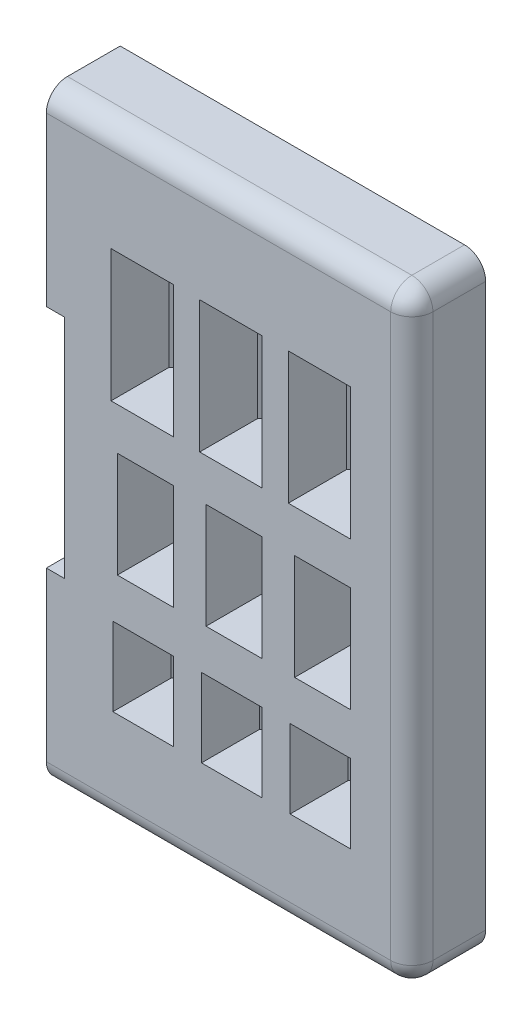
from build123d import *

# Parameters (mm, degrees)
CROQUIS1_W              = 5.9
CROQUIS1_H              = 12.5
CROQUIS1_W_2            = 5.3
CROQUIS1_H_2            = 10
CROQUIS1_W_3            = 5.7277
CROQUIS1_H_3            = 7.4295
SALIENTE_EXTRUIR1_DEPTH = 1
CROQUIS2_W              = 5.9
CROQUIS2_H              = 12.5
CROQUIS2_W_2            = 5.3
CROQUIS2_H_2            = 10
CROQUIS2_W_3            = 5.7277
CROQUIS2_H_3            = 7.4295
SALIENTE_EXTRUIR2_DEPTH = 7
CROQUIS3_W              = 1.2
CROQUIS3_H              = 7.4295
CROQUIS3_H_2            = 10
CROQUIS3_H_3            = 12.5
SALIENTE_EXTRUIR3_DEPTH = 1.5
CHAFL_N1_SIZE           = 1
REDONDEO1_R             = 2


with BuildPart() as part:
    # Croquis1 → Saliente-Extruir1 (new body)
    with BuildSketch(Plane.XY):
        with BuildLine():
            Line((6.325110646, 1.27705094), (31.213497595, 1.27705094))
            ThreePointArc((31.213497595, 1.27705094), (33.334817939, 2.155730596), (34.213497595, 4.27705094))
            Line((34.213497595, 4.27705094), (34.213497595, 46.12294906))
            ThreePointArc((34.213497595, 46.12294906), (33.334817939, 48.244269404), (31.213497595, 49.12294906))
            Line((31.213497595, 49.12294906), (6.325110646, 49.12294906))
            Line((6.325110646, 49.12294906), (6.325110646, 35.928313067))
            Line((6.325110646, 35.928313067), (7.004112389, 35.928313067))
            Line((7.004112389, 35.928313067), (7.004112389, 14.471686933))
            Line((7.004112389, 14.471686933), (6.325110646, 14.471686933))
            Line((6.325110646, 14.471686933), (6.325110646, 1.27705094))
        make_face()
        with Locations((27.45822767, 37.510466453)):
            Rectangle(CROQUIS1_W, CROQUIS1_H, mode=Mode.SUBTRACT)
        with Locations((27.75822767, 22.260466453)):
            Rectangle(CROQUIS1_W_2, CROQUIS1_H_2, mode=Mode.SUBTRACT)
        with Locations((27.54437767, 9.545716453)):
            Rectangle(CROQUIS1_W_3, CROQUIS1_H_3, mode=Mode.SUBTRACT)
        with Locations((19.05822767, 37.510466453)):
            Rectangle(CROQUIS1_W, CROQUIS1_H, mode=Mode.SUBTRACT)
        with Locations((19.35822767, 22.260466453)):
            Rectangle(CROQUIS1_W_2, CROQUIS1_H_2, mode=Mode.SUBTRACT)
        with Locations((19.14437767, 9.545716453)):
            Rectangle(CROQUIS1_W_3, CROQUIS1_H_3, mode=Mode.SUBTRACT)
        with Locations((10.65822767, 37.510466453)):
            Rectangle(CROQUIS1_W, CROQUIS1_H, mode=Mode.SUBTRACT)
        with Locations((10.95822767, 22.260466453)):
            Rectangle(CROQUIS1_W_2, CROQUIS1_H_2, mode=Mode.SUBTRACT)
        with Locations((10.74437767, 9.545716453)):
            Rectangle(CROQUIS1_W_3, CROQUIS1_H_3, mode=Mode.SUBTRACT)
    extrude(amount=-SALIENTE_EXTRUIR1_DEPTH)

    # Croquis2 → Saliente-Extruir2 (add)
    with BuildSketch(Plane.XY):
        Polygon((36.213497595, 53.820046244), (1.576275643, 53.820046244), (1.576275643, 35.928313067), (3.319198905, 35.928313067), (3.319198905, 14.471686933), (1.576275643, 14.471686933), (1.576275643, -3.420839566), (36.213497595, -3.420839566), align=None)
        with Locations((27.45822767, 37.510466453)):
            Rectangle(CROQUIS2_W, CROQUIS2_H, mode=Mode.SUBTRACT)
        with Locations((27.75822767, 22.260466453)):
            Rectangle(CROQUIS2_W_2, CROQUIS2_H_2, mode=Mode.SUBTRACT)
        with Locations((27.54437767, 9.545716453)):
            Rectangle(CROQUIS2_W_3, CROQUIS2_H_3, mode=Mode.SUBTRACT)
        with Locations((19.14437767, 9.545716453)):
            Rectangle(CROQUIS2_W_3, CROQUIS2_H_3, mode=Mode.SUBTRACT)
        with Locations((19.35822767, 22.260466453)):
            Rectangle(CROQUIS2_W_2, CROQUIS2_H_2, mode=Mode.SUBTRACT)
        with Locations((19.05822767, 37.510466453)):
            Rectangle(CROQUIS2_W, CROQUIS2_H, mode=Mode.SUBTRACT)
        with Locations((10.65822767, 37.510466453)):
            Rectangle(CROQUIS2_W, CROQUIS2_H, mode=Mode.SUBTRACT)
        with Locations((10.95822767, 22.260466453)):
            Rectangle(CROQUIS2_W_2, CROQUIS2_H_2, mode=Mode.SUBTRACT)
        with Locations((10.74437767, 9.545716453)):
            Rectangle(CROQUIS2_W_3, CROQUIS2_H_3, mode=Mode.SUBTRACT)
    extrude(amount=SALIENTE_EXTRUIR2_DEPTH)

    # Croquis3 → Saliente-Extruir3 (add)
    with BuildSketch(Plane(origin=(0, 0, -1), x_dir=(-1, 0, 0), z_dir=(0, 0, -1))):
        with Locations((-29.80822767, 9.545716453)):
            Rectangle(CROQUIS3_W, CROQUIS3_H)
        with Locations((-21.40822767, 9.545716453)):
            Rectangle(CROQUIS3_W, CROQUIS3_H)
        with Locations((-25.28052767, 9.545716453)):
            Rectangle(CROQUIS3_W, CROQUIS3_H)
        with Locations((-16.88052767, 9.545716453)):
            Rectangle(CROQUIS3_W, CROQUIS3_H)
        with Locations((-13.00822767, 9.545716453)):
            Rectangle(CROQUIS3_W, CROQUIS3_H)
        with Locations((-8.48052767, 9.545716453)):
            Rectangle(CROQUIS3_W, CROQUIS3_H)
        with Locations((-29.80822767, 22.260466453)):
            Rectangle(CROQUIS3_W, CROQUIS3_H_2)
        with Locations((-21.40822767, 22.260466453)):
            Rectangle(CROQUIS3_W, CROQUIS3_H_2)
        with Locations((-25.70822767, 22.260466453)):
            Rectangle(CROQUIS3_W, CROQUIS3_H_2)
        with Locations((-17.30822767, 22.260466453)):
            Rectangle(CROQUIS3_W, CROQUIS3_H_2)
        with Locations((-13.00822767, 22.260466453)):
            Rectangle(CROQUIS3_W, CROQUIS3_H_2)
        with Locations((-8.90822767, 22.260466453)):
            Rectangle(CROQUIS3_W, CROQUIS3_H_2)
        with Locations((-29.80822767, 37.510466453)):
            Rectangle(CROQUIS3_W, CROQUIS3_H_3)
        with Locations((-25.10822767, 37.510466453)):
            Rectangle(CROQUIS3_W, CROQUIS3_H_3)
        with Locations((-21.40822767, 37.510466453)):
            Rectangle(CROQUIS3_W, CROQUIS3_H_3)
        with Locations((-16.70822767, 37.510466453)):
            Rectangle(CROQUIS3_W, CROQUIS3_H_3)
        with Locations((-13.00822767, 37.510466453)):
            Rectangle(CROQUIS3_W, CROQUIS3_H_3)
        with Locations((-8.30822767, 37.510466453)):
            Rectangle(CROQUIS3_W, CROQUIS3_H_3)
    extrude(amount=-SALIENTE_EXTRUIR3_DEPTH)

    # Chaflán1
    chafl_n1_edges = [part.edges().sort_by_distance(p)[0] for p in [
        (30.40822767, 9.545716453, 0.5),
        (24.68052767, 9.545716453, 0.5),
        (22.00822767, 9.545716453, 0.5),
        (16.28052767, 9.545716453, 0.5),
        (13.60822767, 9.545716453, 0.5),
        (7.88052767, 9.545716453, 0.5),
        (30.40822767, 22.260466453, 0.5),
        (25.10822767, 22.260466453, 0.5),
        (22.00822767, 22.260466453, 0.5),
        (16.70822767, 22.260466453, 0.5),
        (13.60822767, 22.260466453, 0.5),
        (8.30822767, 22.260466453, 0.5),
        (30.40822767, 37.510466453, 0.5),
        (24.50822767, 37.510466453, 0.5),
        (22.00822767, 37.510466453, 0.5),
        (16.10822767, 37.510466453, 0.5),
        (13.60822767, 37.510466453, 0.5),
        (7.70822767, 37.510466453, 0.5),
    ]]
    chamfer(chafl_n1_edges, length=CHAFL_N1_SIZE)

    # Redondeo1
    redondeo1_edges = [part.edges().sort_by_distance(p)[0] for p in [
        (18.894886619, -3.420839566, 7),
        (36.213497595, 25.199603339, 7),
        (18.894886619, 53.820046244, 7),
        (36.213497595, -3.420839566, 3.5),
        (36.213497595, 53.820046244, 3.5),
    ]]
    fillet(redondeo1_edges, radius=REDONDEO1_R)


solid = part.part
